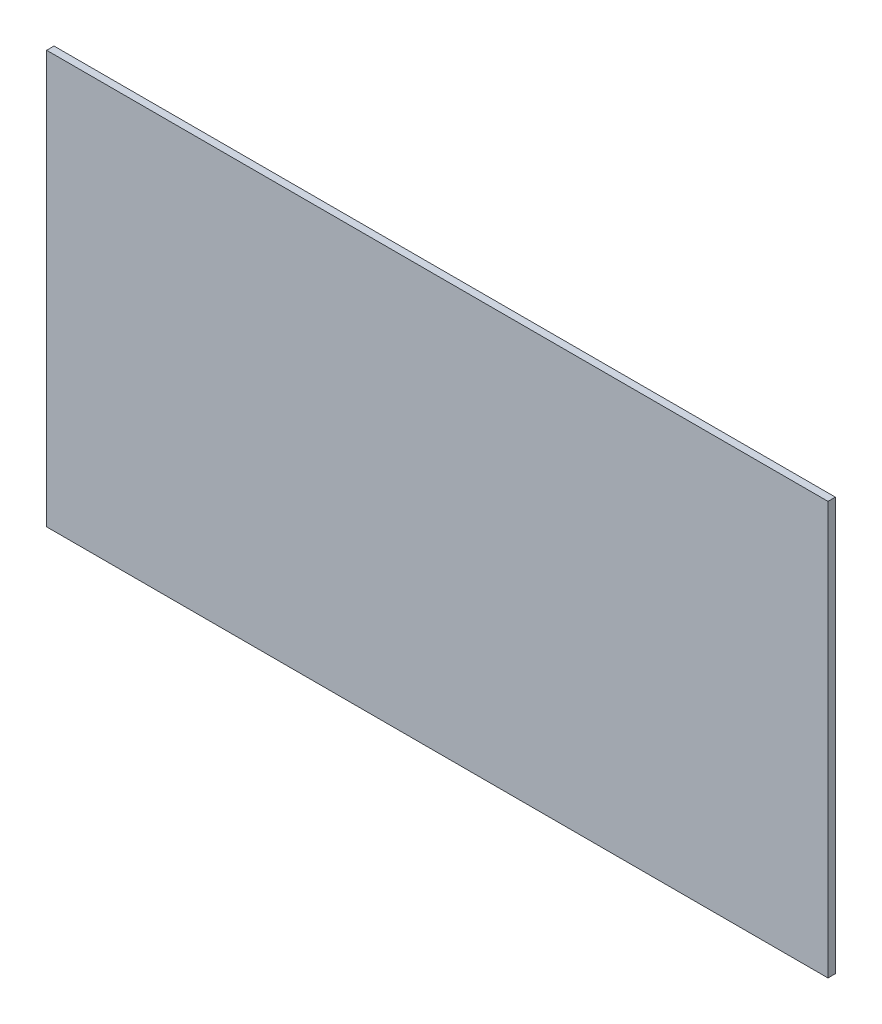
from build123d import *

# Parameters (mm, degrees)
SKETCH1_W           = 212
SKETCH1_H           = 112
BOSS_EXTRUDE1_DEPTH = 2


with BuildPart() as part:
    # Sketch1 → Boss-Extrude1 (new body)
    with BuildSketch(Plane.XY):
        Rectangle(SKETCH1_W, SKETCH1_H)
    extrude(amount=BOSS_EXTRUDE1_DEPTH)


solid = part.part
